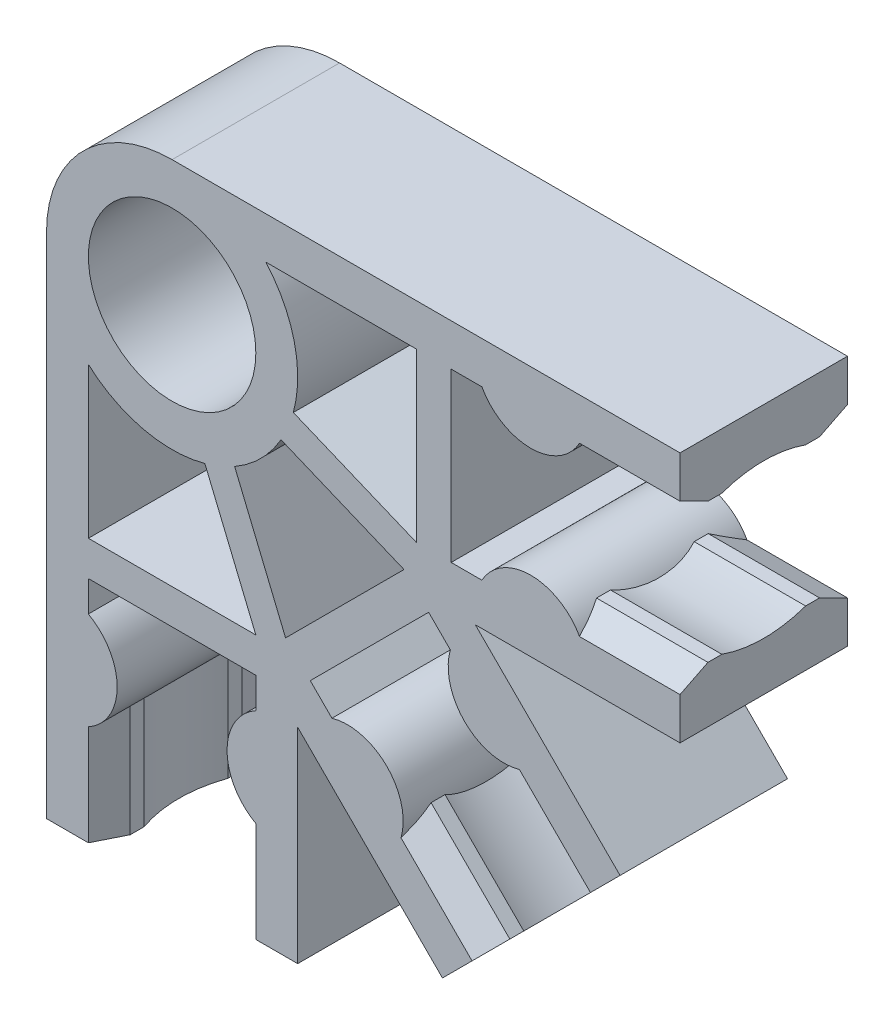
from build123d import *

# Parameters (mm, degrees)
EXTRUDE_1_DEPTH          = 6
EXTRUDE_2_REACH          = 25.907
PATTERN_CIRCULAR_1_COUNT = 3
PATTERN_CIRCULAR_1_ANGLE = 90
SKETCH_4_R               = 3
CUT_EXTRUDE_1_DEPTH      = 27.42877236


with BuildPart() as part:
    # 草图1 → 凸台-拉伸1 (new body)
    with BuildSketch(Plane.XY):
        with BuildLine():
            Line((-4.5, 0), (-4.5, -18.2))
            Line((-4.5, -18.2), (-3, -18.2))
            Line((-3, -18.2), (-3, -14.6))
            ThreePointArc((-3, -14.6), (-1.968245837, -12.85), (-3, -11.1))
            Line((-3, -11.1), (-3, -10))
            Line((-3, -10), (3, -10))
            Line((3, -10), (3, -11.1))
            ThreePointArc((3, -11.1), (1.968245837, -12.85), (3, -14.6))
            Line((3, -14.6), (3, -18.2))
            Line((3, -18.2), (4.5, -18.2))
            Line((4.5, -18.2), (4.5, 0))
            ThreePointArc((4.5, 0), (0, 4.5), (-4.5, 0))
        make_face()
    extrude_1 = extrude(amount=EXTRUDE_1_DEPTH)

    # 草图3 → 凸台-拉伸2 (add, up to next)
    with BuildSketch(Plane.XZ.offset(18.2), mode=Mode.PRIVATE) as extrude_2_sk1:
        with BuildLine():
            Line((-3, 6), (-3, 0))
            Line((-3, 0), (-2.5, 1))
            Line((-2.5, 1), (-2.5, 1.5))
            ThreePointArc((-2.5, 1.5), (-2.757359313, 3), (-2.5, 4.5))
            Line((-2.5, 4.5), (-2.5, 5))
            Line((-2.5, 5), (-3, 6))
        make_face()
    extrude_2_tool1 = extrude(extrude_2_sk1.sketch, amount=-EXTRUDE_2_REACH, mode=Mode.PRIVATE) - part.part
    # 草图3 → 凸台-拉伸2 (add, up to next)
    with BuildSketch(Plane.XZ.offset(18.2), mode=Mode.PRIVATE) as extrude_2_sk2:
        with BuildLine():
            Line((3, 0), (2.5, 1))
            Line((2.5, 1), (2.5, 1.5))
            ThreePointArc((2.5, 1.5), (2.757359313, 3), (2.5, 4.5))
            Line((2.5, 4.5), (2.5, 5))
            Line((2.5, 5), (3, 6))
            Line((3, 6), (3, 0))
        make_face()
    extrude_2_tool2 = extrude(extrude_2_sk2.sketch, amount=-EXTRUDE_2_REACH, mode=Mode.PRIVATE) - part.part
    extrude_2_1 = extrude_2_tool1.solids().sort_by_distance((-2.809362, -18.2, 3))[0]
    add(extrude_2_1)
    extrude_2_2 = extrude_2_tool2.solids().sort_by_distance((2.809362, -18.2, 3))[0]
    add(extrude_2_2)
    extrude_2 = extrude_2_1 + extrude_2_2  # 凸台-拉伸2 as one shape, for the pattern or mirror that repeats it

    # 阵列(圆周)1: 凸台-拉伸1, 凸台-拉伸2 ×3 about axis
    pattern_circular_1_axis = Axis((0, 0, 0), (0, 0, 1))
    add([extrude_1.rotate(pattern_circular_1_axis, i * PATTERN_CIRCULAR_1_ANGLE / (PATTERN_CIRCULAR_1_COUNT - 1)) for i in range(1, PATTERN_CIRCULAR_1_COUNT)])
    add([extrude_2.rotate(pattern_circular_1_axis, i * PATTERN_CIRCULAR_1_ANGLE / (PATTERN_CIRCULAR_1_COUNT - 1)) for i in range(1, PATTERN_CIRCULAR_1_COUNT)])

    # 草图4 → 切除-拉伸1 (cut, through all)
    with BuildSketch(Plane.XY.offset(6)):
        Circle(SKETCH_4_R)
        with BuildLine():
            Line((8.75, 3), (3.354101966, 3))
            ThreePointArc((3.354101966, 3), (4.378625055, 1.038095674), (4.343906601, -1.174936357))
            Line((4.343906601, -1.174936357), (8.75, -3))
            Line((8.75, -3), (8.75, 3))
        make_face()
        with BuildLine():
            Line((3, -8.75), (1.174936357, -4.343906601))
            ThreePointArc((1.174936357, -4.343906601), (-1.038095674, -4.378625055), (-3, -3.354101966))
            Line((-3, -3.354101966), (-3, -8.75))
            Line((-3, -8.75), (3, -8.75))
        make_face()
        with BuildLine():
            Line((8.308504679, -4.065863992), (4.065863992, -8.308504679))
            Line((4.065863992, -8.308504679), (2.240800349, -3.90241128))
            ThreePointArc((2.240800349, -3.90241128), (3.181980515, -3.181980515), (3.90241128, -2.240800349))
            Line((3.90241128, -2.240800349), (8.308504679, -4.065863992))
        make_face()
    extrude(amount=-CUT_EXTRUDE_1_DEPTH, mode=Mode.SUBTRACT)


solid = part.part
